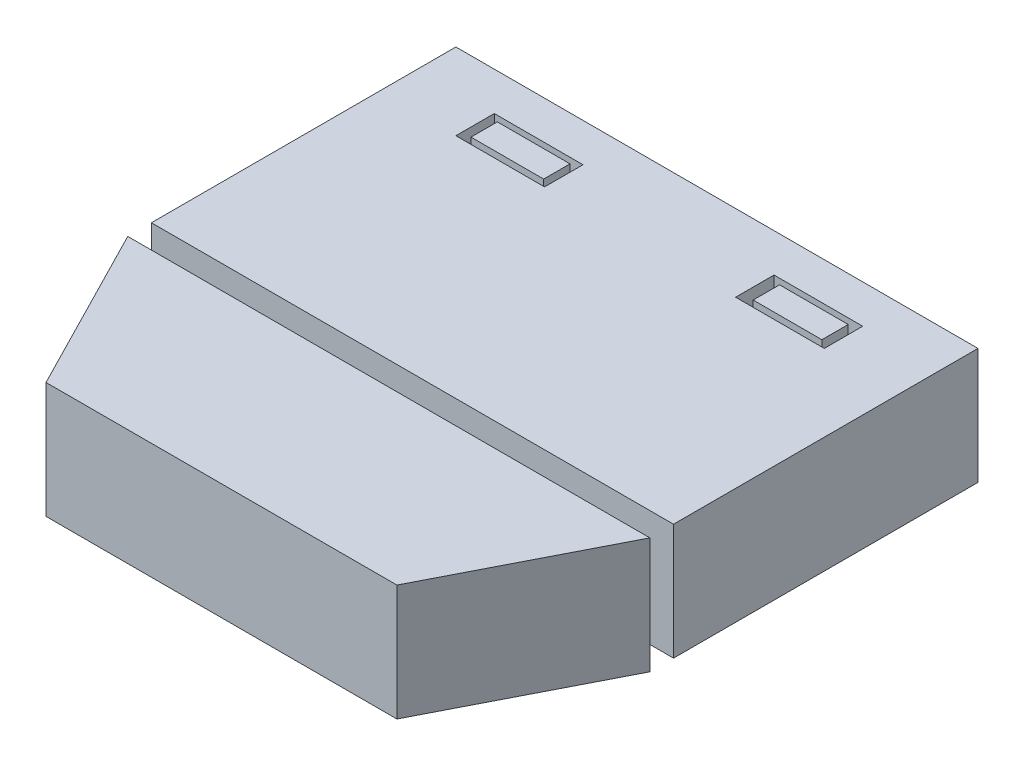
from build123d import *

# Parameters (mm, degrees)
BOSS_EXTRUDE3_DEPTH   = 10
SKETCH1_W             = 45
SKETCH1_H             = 26.242038217
SKETCH1_W_2           = 7.643312102
SKETCH1_H_2           = 3.312101911
BOSS_EXTRUDE3_2_DEPTH = 10
SKETCH1_W_3           = 6.263973538
SKETCH1_H_3           = 2.271386604
BOSS_EXTRUDE3_3_DEPTH = 10
SKETCH1_W_4           = 5.923265548
BOSS_EXTRUDE3_4_DEPTH = 10


with BuildPart() as part:
    # Sketch1 → Boss-Extrude3 (new body)
    with BuildSketch(Plane(origin=(0, 0, 0), x_dir=(1, 0, 0), z_dir=(0, 1, 0))):
        Polygon((7.377618706, -2.703877559), (22.5, -2.703877559), (37.622381294, -2.703877559), (45, 11.719745223), (0, 11.719745223), align=None)
    extrude(amount=BOSS_EXTRUDE3_DEPTH)


with BuildPart() as body_2:
    # Sketch1 → Boss-Extrude3 2 (new body)
    with BuildSketch(Plane(origin=(0, 0, 0), x_dir=(1, 0, 0), z_dir=(0, 1, 0))):
        with Locations((22.5, 26.878980891)):
            Rectangle(SKETCH1_W, SKETCH1_H)
        with Locations((34.554140127, 35.031847134)):
            Rectangle(SKETCH1_W_2, SKETCH1_H_2, mode=Mode.SUBTRACT)
        with Locations((10.445859873, 35.031847134)):
            Rectangle(SKETCH1_W_2, SKETCH1_H_2, mode=Mode.SUBTRACT)
    extrude(amount=BOSS_EXTRUDE3_2_DEPTH)


with BuildPart() as body_3:
    # Sketch1 → Boss-Extrude3 3 (new body)
    with BuildSketch(Plane(origin=(0, 0, 0), x_dir=(1, 0, 0), z_dir=(0, 1, 0))):
        with Locations((10.509605475, 35.058829435)):
            Rectangle(SKETCH1_W_3, SKETCH1_H_3)
    extrude(amount=BOSS_EXTRUDE3_3_DEPTH)


with BuildPart() as body_4:
    # Sketch1 → Boss-Extrude3 4 (new body)
    with BuildSketch(Plane(origin=(0, 0, 0), x_dir=(1, 0, 0), z_dir=(0, 1, 0))):
        with Locations((34.66074852, 35.058829435)):
            Rectangle(SKETCH1_W_4, SKETCH1_H_3)
    extrude(amount=BOSS_EXTRUDE3_4_DEPTH)


solid = Compound([part.part, body_2.part, body_3.part, body_4.part])
